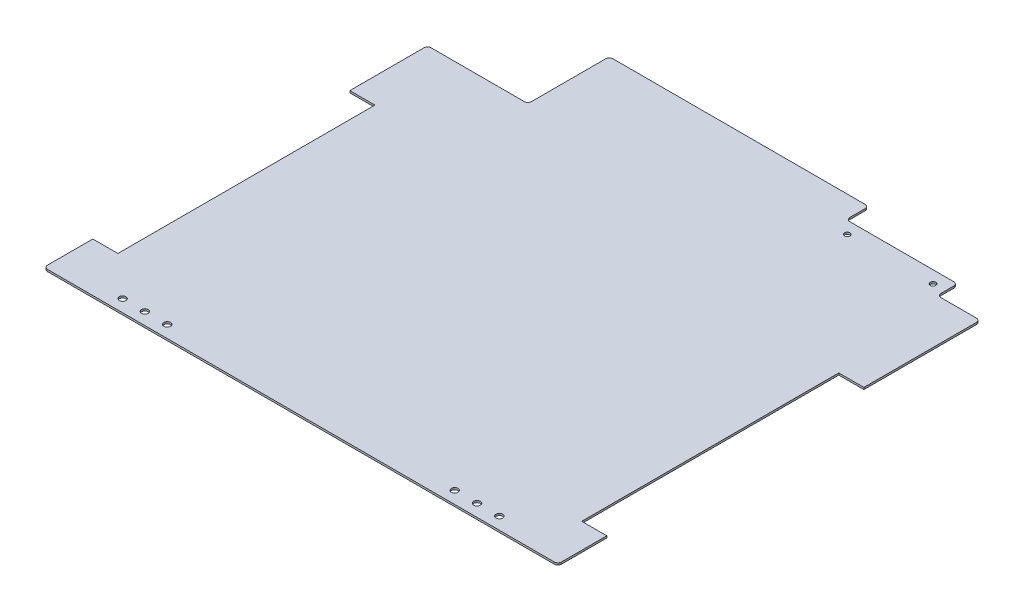
from build123d import *

# Parameters (mm, degrees)
BOSS_EXTRUDE1_DEPTH     = 1.5875
M5_CLEARANCE_HOLE1_D    = 5.5
SKETCH11_W              = 91
SKETCH11_H              = 18.5
CUT_EXTRUDE1_DEPTH      = 1
CUT_EXTRUDE1_DEPTH_BACK = 2.5875
M4_CLEARANCE_HOLE1_D    = 4.5
FILLET1_R               = 3
SKETCH15_W              = 20.5
SKETCH15_H              = 210
CUT_EXTRUDE2_DEPTH      = 1
CUT_EXTRUDE2_DEPTH_BACK = 2.5875


with BuildPart() as part:
    # Sketch1 → Boss-Extrude1 (new body)
    with BuildSketch(Plane(origin=(0, 0, 0), x_dir=(1, 0, 0), z_dir=(0, 1, 0))):
        Polygon((91.75, -187.647941311), (-208.25, -187.647941311), (-208.25, 92.973423913), (-208.25, 125.872458689), (-126.25, 125.872458689), (-126.25, 192.372458689), (-117.25, 192.372458689), (176.75, 192.372458689), (176.75, 157.382658689), (211.75, 157.382658689), (211.75, -157.627541311), (211.75, -187.647941311), align=None)
    extrude(amount=BOSS_EXTRUDE1_DEPTH)

    # M5 Clearance Hole1 (through all)
    with Locations(Plane(origin=(0, 1.5875, 0), x_dir=(1, 0, 0), z_dir=(0, 1, 0))):
        with Locations((-153.937540098, -177.647941311), (-135.677540098, -177.647941311), (-117.417540098, -177.647941311), (117.417540098, -177.647941311), (135.677540098, -177.647941311), (153.937540098, -177.647941311)):
            Hole(M5_CLEARANCE_HOLE1_D / 2)

    # Sketch11 → Cut-Extrude1 (cut, two sides)
    with BuildSketch(Plane(origin=(0, 1.5875, 0), x_dir=(1, 0, 0), z_dir=(0, 1, 0))) as cut_extrude1_sk:
        with Locations((131.25, 183.122458689)):
            Rectangle(SKETCH11_W, SKETCH11_H)
    extrude(amount=CUT_EXTRUDE1_DEPTH, mode=Mode.SUBTRACT)
    extrude(cut_extrude1_sk.sketch, amount=-CUT_EXTRUDE1_DEPTH_BACK, mode=Mode.SUBTRACT)

    # M4 Clearance Hole1 (through all)
    with Locations(Plane(origin=(0, 1.5875, 0), x_dir=(1, 0, 0), z_dir=(0, 1, 0))):
        with Locations((96.75, 163.872458689), (166.75, 163.872458689)):
            Hole(M4_CLEARANCE_HOLE1_D / 2)

    # Fillet1
    fillet1_edges = [part.edges().sort_by_distance(p)[0] for p in [
        (211.75, 0.79375, 187.647941311),
        (-208.25, 0.79375, 187.647941311),
        (-208.25, 0.79375, -125.872458689),
        (-126.25, 0.79375, -125.872458689),
        (-126.25, 0.79375, -192.372458689),
        (176.75, 0.79375, -157.382658689),
        (211.75, 0.79375, -157.382658689),
        (176.75, 0.79375, -173.872458689),
        (85.75, 0.79375, -173.872458689),
        (85.75, 0.79375, -192.372458689),
    ]]
    fillet(fillet1_edges, radius=FILLET1_R)

    # Sketch15 → Cut-Extrude2 (cut, two sides)
    with BuildSketch(Plane(origin=(0, 1.5875, 0), x_dir=(1, 0, 0), z_dir=(0, 1, 0))) as cut_extrude2_sk:
        with Locations((-198, -42.647941311)):
            Rectangle(SKETCH15_W, SKETCH15_H)
        with Locations((201.5, -42.647941311)):
            Rectangle(SKETCH15_W, SKETCH15_H)
    extrude(amount=CUT_EXTRUDE2_DEPTH, mode=Mode.SUBTRACT)
    extrude(cut_extrude2_sk.sketch, amount=-CUT_EXTRUDE2_DEPTH_BACK, mode=Mode.SUBTRACT)


solid = part.part
